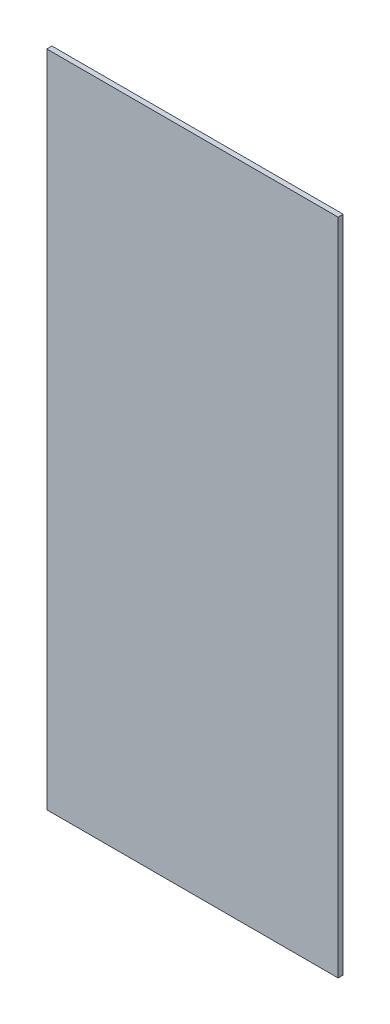
from build123d import *

# Parameters (mm, degrees)
SKETCH1_W           = 575
SKETCH1_H           = 1300.5
BOSS_EXTRUDE1_DEPTH = 10


with BuildPart() as part:
    # Sketch1 → Boss-Extrude1 (new body)
    with BuildSketch(Plane.XY):
        Rectangle(SKETCH1_W, SKETCH1_H)
    extrude(amount=BOSS_EXTRUDE1_DEPTH)


solid = part.part
